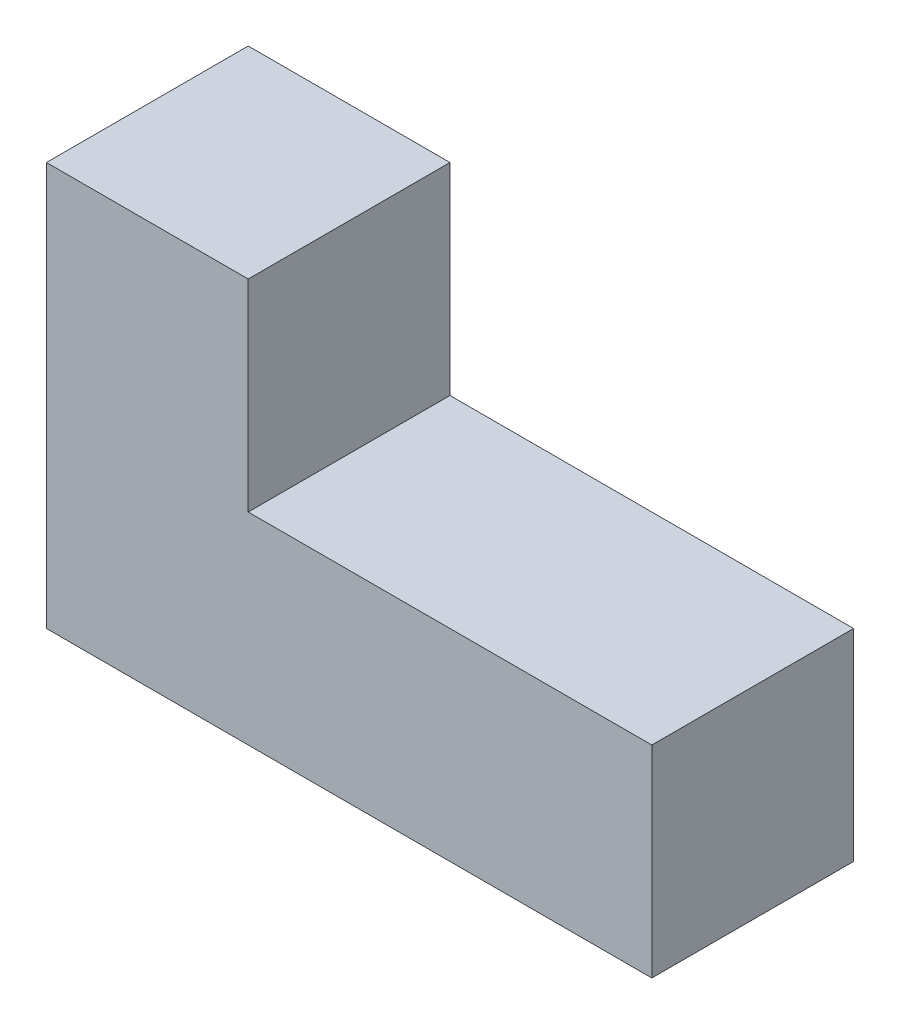
from build123d import *

# Parameters (mm, degrees)
BOSS_EXTRUDE1_DEPTH = 30


with BuildPart() as part:
    # Sketch2 → Boss-Extrude1 (new body)
    with BuildSketch(Plane.XY):
        Polygon((0, 0), (90, 0), (90, 30), (30, 30), (30, 60), (0, 60), align=None)
    extrude(amount=BOSS_EXTRUDE1_DEPTH)


solid = part.part
